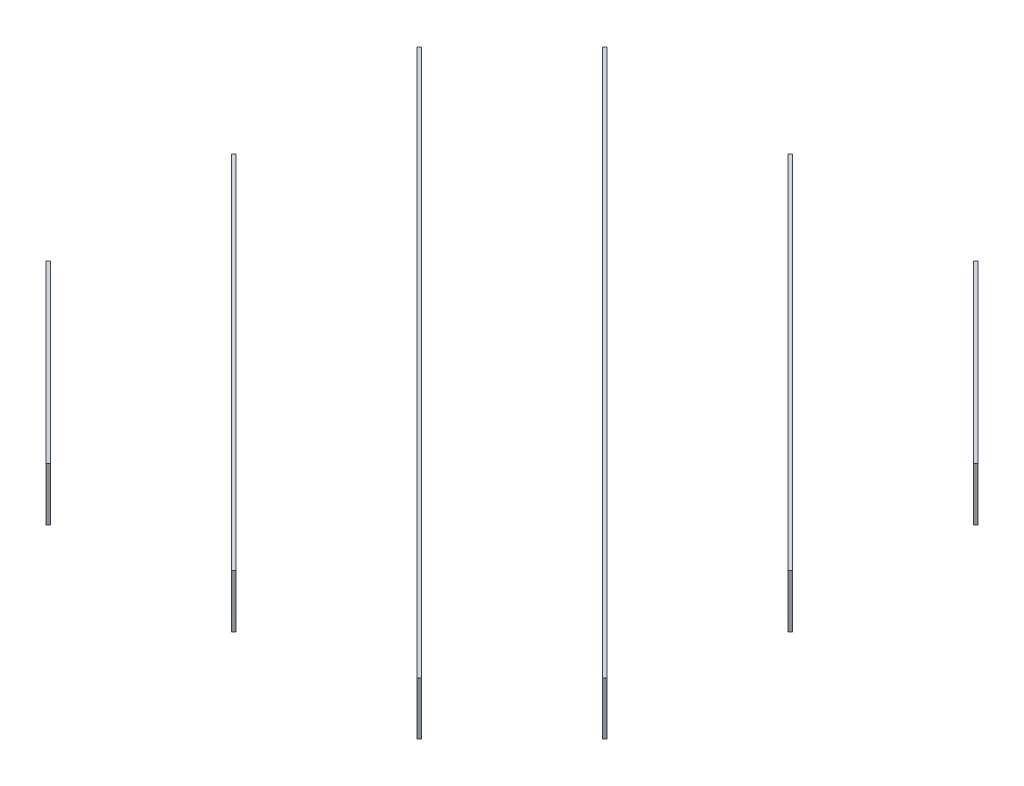
from build123d import *

# Parameters (mm, degrees)
BOSS_EXTRUDE1_DEPTH   = 100
BOSS_EXTRUDE1_2_DEPTH = 100
BOSS_EXTRUDE1_3_DEPTH = 100
BOSS_EXTRUDE1_4_DEPTH = 100
BOSS_EXTRUDE1_5_DEPTH = 100
BOSS_EXTRUDE1_6_DEPTH = 100
SKETCH3_R             = 1.5
SKETCH3_W             = 6
SKETCH3_H             = 100
CUT_EXTRUDE1_DEPTH    = 1478.317638774
SKETCH6_W             = 56
SKETCH6_H             = 12
CUT_EXTRUDE3_DEPTH    = 6
SKETCH7_W             = 56
SKETCH7_H             = 12
CUT_EXTRUDE4_DEPTH    = 6
SKETCH8_R             = 1.5
CUT_EXTRUDE5_DEPTH    = 1478.317638774
CUT_EXTRUDE6_START    = -253.487374
SKETCH9_R             = 4
CUT_EXTRUDE6_DEPTH    = 253.487374
CUT_EXTRUDE7_START    = -253.487374
SKETCH10_R            = 3
CUT_EXTRUDE7_DEPTH    = 253.487374
CUT_EXTRUDE8_START    = -253.487374
SKETCH11_R            = 3
CUT_EXTRUDE8_DEPTH    = 253.487374
SKETCH12_R            = 3
CUT_EXTRUDE9_DEPTH    = 748.46212
CUT_EXTRUDE10_START   = -253.487374
SKETCH13_R            = 3
CUT_EXTRUDE10_DEPTH   = 253.487374


with BuildPart() as part:
    # Sketch2 → Boss-Extrude1 (new body)
    with BuildSketch(Plane(origin=(0, 0, 0), x_dir=(1, 0, 0), z_dir=(0, 1, 0))):
        Polygon((-605, -274.242640687), (-274.242640687, -605), (-270, -600.757359313), (-600.757359313, -270), align=None)
    extrude(amount=BOSS_EXTRUDE1_DEPTH)


with BuildPart() as body_2:
    # Sketch2 → Boss-Extrude1 2 (new body)
    with BuildSketch(Plane(origin=(0, 0, 0), x_dir=(1, 0, 0), z_dir=(0, 1, 0))):
        Polygon((-605, 75.757359313), (75.757359313, -605), (80, -600.757359313), (-600.757359313, 80), align=None)
    extrude(amount=BOSS_EXTRUDE1_2_DEPTH)


with BuildPart() as body_3:
    # Sketch2 → Boss-Extrude1 3 (new body)
    with BuildSketch(Plane(origin=(0, 0, 0), x_dir=(1, 0, 0), z_dir=(0, 1, 0))):
        Polygon((-605, 425.757359313), (425.757359313, -605), (430, -600.757359313), (-600.757359313, 430), align=None)
    extrude(amount=BOSS_EXTRUDE1_3_DEPTH)


with BuildPart() as body_4:
    # Sketch2 → Boss-Extrude1 4 (new body)
    with BuildSketch(Plane(origin=(0, 0, 0), x_dir=(1, 0, 0), z_dir=(0, 1, 0))):
        Polygon((-430, 600.757359313), (600.757359313, -430), (605, -425.757359313), (-425.757359313, 605), align=None)
    extrude(amount=BOSS_EXTRUDE1_4_DEPTH)


with BuildPart() as body_5:
    # Sketch2 → Boss-Extrude1 5 (new body)
    with BuildSketch(Plane(origin=(0, 0, 0), x_dir=(1, 0, 0), z_dir=(0, 1, 0))):
        Polygon((-80, 600.757359313), (600.757359313, -80), (605, -75.757359313), (-75.757359313, 605), align=None)
    extrude(amount=BOSS_EXTRUDE1_5_DEPTH)


with BuildPart() as body_6:
    # Sketch2 → Boss-Extrude1 6 (new body)
    with BuildSketch(Plane(origin=(0, 0, 0), x_dir=(1, 0, 0), z_dir=(0, 1, 0))):
        Polygon((270, 600.757359313), (600.757359313, 270), (605, 274.242640687), (274.242640687, 605), align=None)
    extrude(amount=BOSS_EXTRUDE1_6_DEPTH)


with BuildPart() as cut_extrude1_tool:
    # Sketch3 → Cut-Extrude1 (new body, through all)
    with BuildSketch(Plane(origin=(-439.621320344, 0, 439.621320344), x_dir=(0.707106781, 0, 0.707106781), z_dir=(-0.707106781, 0, 0.707106781))):
        with Locations((-615.718433538, 50)):
            Circle(SKETCH3_R)
        with Locations((-621.718433538, 50)):
            Circle(SKETCH3_R)
        with Locations((-618.718433538, 0)):
            Rectangle(SKETCH3_W, SKETCH3_H)
        with BuildLine():
            Line((-621.718433538, 48.5), (-621.718433538, 50))
            Line((-621.718433538, 50), (-620.218433538, 50))
            ThreePointArc((-620.218433538, 50), (-622.77909371, 51.060660172), (-621.718433538, 48.5))
        make_face()
        with BuildLine():
            Line((-620.218433538, 50), (-621.718433538, 50))
            Line((-621.718433538, 50), (-621.718433538, 48.5))
            ThreePointArc((-621.718433538, 48.5), (-620.657773366, 48.939339828), (-620.218433538, 50))
        make_face()
        with BuildLine():
            ThreePointArc((-614.218433538, 50), (-615.718433538, 51.5), (-617.218433538, 50))
            Line((-617.218433538, 50), (-615.718433538, 50))
            Line((-615.718433538, 50), (-615.718433538, 48.5))
            ThreePointArc((-615.718433538, 48.5), (-614.657773366, 48.939339828), (-614.218433538, 50))
        make_face()
        with BuildLine():
            Line((-615.718433538, 50), (-617.218433538, 50))
            ThreePointArc((-617.218433538, 50), (-616.77909371, 48.939339828), (-615.718433538, 48.5))
            Line((-615.718433538, 48.5), (-615.718433538, 50))
        make_face()
        with BuildLine():
            Line((-374.231060123, 48.5), (-374.231060123, 50))
            Line((-374.231060123, 50), (-372.731060123, 50))
            ThreePointArc((-372.731060123, 50), (-375.291720295, 51.060660172), (-374.231060123, 48.5))
        make_face()
        with BuildLine():
            Line((-372.731060123, 50), (-374.231060123, 50))
            Line((-374.231060123, 50), (-374.231060123, 48.5))
            ThreePointArc((-374.231060123, 48.5), (-373.170399951, 48.939339828), (-372.731060123, 50))
        make_face()
        with Locations((-368.231060123, 50)):
            Circle(SKETCH3_R)
        with Locations((-374.231060123, 50)):
            Circle(SKETCH3_R)
        with Locations((-371.231060123, 0)):
            Rectangle(SKETCH3_W, SKETCH3_H)
        with BuildLine():
            ThreePointArc((-366.731060123, 50), (-368.231060123, 51.5), (-369.731060123, 50))
            Line((-369.731060123, 50), (-368.231060123, 50))
            Line((-368.231060123, 50), (-368.231060123, 48.5))
            ThreePointArc((-368.231060123, 48.5), (-367.170399951, 48.939339828), (-366.731060123, 50))
        make_face()
        with BuildLine():
            Line((-368.231060123, 50), (-369.731060123, 50))
            ThreePointArc((-369.731060123, 50), (-369.291720295, 48.939339828), (-368.231060123, 48.5))
            Line((-368.231060123, 48.5), (-368.231060123, 50))
        make_face()
        with BuildLine():
            Line((-126.705577884, 48.5), (-126.705577884, 50))
            Line((-126.705577884, 50), (-125.205577884, 50))
            ThreePointArc((-125.205577884, 50), (-127.766238056, 51.060660172), (-126.705577884, 48.5))
        make_face()
        with BuildLine():
            Line((-125.205577884, 50), (-126.705577884, 50))
            Line((-126.705577884, 50), (-126.705577884, 48.5))
            ThreePointArc((-126.705577884, 48.5), (-125.644917713, 48.939339828), (-125.205577884, 50))
        make_face()
        with BuildLine():
            ThreePointArc((-119.205577884, 50), (-120.705577884, 51.5), (-122.205577884, 50))
            Line((-122.205577884, 50), (-120.705577884, 50))
            Line((-120.705577884, 50), (-120.705577884, 48.5))
            ThreePointArc((-120.705577884, 48.5), (-119.644917713, 48.939339828), (-119.205577884, 50))
        make_face()
        with BuildLine():
            Line((-120.705577884, 50), (-122.205577884, 50))
            ThreePointArc((-122.205577884, 50), (-121.766238056, 48.939339828), (-120.705577884, 48.5))
            Line((-120.705577884, 48.5), (-120.705577884, 50))
        make_face()
        with BuildLine():
            Line((-122.205577884, 50), (-125.205577884, 50))
            ThreePointArc((-125.205577884, 50), (-125.644917713, 48.939339828), (-126.705577884, 48.5))
            Line((-126.705577884, 48.5), (-126.705577884, 0))
            Line((-126.705577884, 0), (-120.705577884, 0))
            Line((-120.705577884, 0), (-120.705577884, 48.5))
            ThreePointArc((-120.705577884, 48.5), (-121.766238056, 48.939339828), (-122.205577884, 50))
        make_face()
        with BuildLine():
            ThreePointArc((122.205577884, 50), (119.644917713, 51.060660172), (120.705577884, 48.5))
            Line((120.705577884, 48.5), (120.705577884, 50))
            Line((120.705577884, 50), (122.205577884, 50))
        make_face()
        with BuildLine():
            Line((120.705577884, 50), (120.705577884, 48.5))
            ThreePointArc((120.705577884, 48.5), (121.766238056, 48.939339828), (122.205577884, 50))
            Line((122.205577884, 50), (120.705577884, 50))
        make_face()
        with BuildLine():
            Line((120.705577884, 48.5), (120.705577884, 0))
            Line((120.705577884, 0), (126.705577884, 0))
            Line((126.705577884, 0), (126.705577884, 48.5))
            ThreePointArc((126.705577884, 48.5), (125.644917713, 48.939339828), (125.205577884, 50))
            Line((125.205577884, 50), (122.205577884, 50))
            ThreePointArc((122.205577884, 50), (121.766238056, 48.939339828), (120.705577884, 48.5))
        make_face()
        with BuildLine():
            ThreePointArc((125.205577884, 50), (125.644917713, 48.939339828), (126.705577884, 48.5))
            Line((126.705577884, 48.5), (126.705577884, 50))
            Line((126.705577884, 50), (125.205577884, 50))
        make_face()
        with BuildLine():
            Line((126.705577884, 50), (126.705577884, 48.5))
            ThreePointArc((126.705577884, 48.5), (127.766238056, 48.939339828), (128.205577884, 50))
            ThreePointArc((128.205577884, 50), (126.705577884, 51.5), (125.205577884, 50))
            Line((125.205577884, 50), (126.705577884, 50))
        make_face()
        with BuildLine():
            Line((369.731060123, 50), (368.231060123, 50))
            Line((368.231060123, 50), (368.231060123, 48.5))
            ThreePointArc((368.231060123, 48.5), (369.291720295, 48.939339828), (369.731060123, 50))
        make_face()
        with BuildLine():
            Line((368.231060123, 48.5), (368.231060123, 50))
            Line((368.231060123, 50), (369.731060123, 50))
            ThreePointArc((369.731060123, 50), (367.170399951, 51.060660172), (368.231060123, 48.5))
        make_face()
        with Locations((374.231060123, 50)):
            Circle(SKETCH3_R)
        with Locations((368.231060123, 50)):
            Circle(SKETCH3_R)
        with Locations((371.231060123, 0)):
            Rectangle(SKETCH3_W, SKETCH3_H)
        with BuildLine():
            ThreePointArc((375.731060123, 50), (374.231060123, 51.5), (372.731060123, 50))
            Line((372.731060123, 50), (374.231060123, 50))
            Line((374.231060123, 50), (374.231060123, 48.5))
            ThreePointArc((374.231060123, 48.5), (375.291720295, 48.939339828), (375.731060123, 50))
        make_face()
        with BuildLine():
            Line((374.231060123, 50), (372.731060123, 50))
            ThreePointArc((372.731060123, 50), (373.170399951, 48.939339828), (374.231060123, 48.5))
            Line((374.231060123, 48.5), (374.231060123, 50))
        make_face()
        with BuildLine():
            Line((617.218433538, 50), (615.718433538, 50))
            Line((615.718433538, 50), (615.718433538, 48.5))
            ThreePointArc((615.718433538, 48.5), (616.77909371, 48.939339828), (617.218433538, 50))
        make_face()
        with BuildLine():
            Line((615.718433538, 48.5), (615.718433538, 50))
            Line((615.718433538, 50), (617.218433538, 50))
            ThreePointArc((617.218433538, 50), (614.657773366, 51.060660172), (615.718433538, 48.5))
        make_face()
        with BuildLine():
            ThreePointArc((623.218433538, 50), (621.718433538, 51.5), (620.218433538, 50))
            Line((620.218433538, 50), (621.718433538, 50))
            Line((621.718433538, 50), (621.718433538, 48.5))
            ThreePointArc((621.718433538, 48.5), (622.77909371, 48.939339828), (623.218433538, 50))
        make_face()
        with BuildLine():
            Line((621.718433538, 50), (620.218433538, 50))
            ThreePointArc((620.218433538, 50), (620.657773366, 48.939339828), (621.718433538, 48.5))
            Line((621.718433538, 48.5), (621.718433538, 50))
        make_face()
        with Locations((621.718433538, 50)):
            Circle(SKETCH3_R)
        with Locations((615.718433538, 50)):
            Circle(SKETCH3_R)
        with Locations((618.718433538, 0)):
            Rectangle(SKETCH3_W, SKETCH3_H)
    extrude(amount=-CUT_EXTRUDE1_DEPTH)


with BuildPart() as part_1:
    add(part.part)

    # Cut-Extrude1: cut by cut_extrude1_tool
    add(cut_extrude1_tool.part, mode=Mode.SUBTRACT)


with BuildPart() as body_2_1:
    add(body_2.part)

    # Cut-Extrude1: cut by cut_extrude1_tool
    add(cut_extrude1_tool.part, mode=Mode.SUBTRACT)

    # Sketch7 → Cut-Extrude4 (cut)
    with BuildSketch(Plane(origin=(-264.621320344, 0, 264.621320344), x_dir=(0.707106781, 0, 0.707106781), z_dir=(-0.707106781, 0, 0.707106781))):
        with Locations((-0.019054412, 78)):
            Rectangle(SKETCH7_W, SKETCH7_H)
    extrude(amount=-CUT_EXTRUDE4_DEPTH, mode=Mode.SUBTRACT)


with BuildPart() as body_3_1:
    add(body_3.part)

    # Cut-Extrude1: cut by cut_extrude1_tool
    add(cut_extrude1_tool.part, mode=Mode.SUBTRACT)


with BuildPart() as body_4_1:
    add(body_4.part)

    # Cut-Extrude1: cut by cut_extrude1_tool
    add(cut_extrude1_tool.part, mode=Mode.SUBTRACT)


with BuildPart() as body_5_1:
    add(body_5.part)

    # Cut-Extrude1: cut by cut_extrude1_tool
    add(cut_extrude1_tool.part, mode=Mode.SUBTRACT)

    # Sketch6 → Cut-Extrude3 (cut)
    with BuildSketch(Plane(origin=(260.378679656, 0, -260.378679656), x_dir=(0.707106781, 0, 0.707106781), z_dir=(-0.707106781, 0, 0.707106781))):
        with Locations((-0.019054412, 78)):
            Rectangle(SKETCH6_W, SKETCH6_H)
    extrude(amount=-CUT_EXTRUDE3_DEPTH, mode=Mode.SUBTRACT)


with BuildPart() as body_6_1:
    add(body_6.part)

    # Cut-Extrude1: cut by cut_extrude1_tool
    add(cut_extrude1_tool.part, mode=Mode.SUBTRACT)


with BuildPart() as cut_extrude5_tool:
    # Sketch8 → Cut-Extrude5 (new body, through all)
    with BuildSketch(Plane(origin=(-439.621320344, 0, 439.621320344), x_dir=(0.707106781, 0, 0.707106781), z_dir=(-0.707106781, 0, 0.707106781))):
        Circle(SKETCH8_R)
    extrude(amount=-CUT_EXTRUDE5_DEPTH)


with BuildPart() as part_2:
    add(part_1.part)

    # Cut-Extrude5: cut by cut_extrude5_tool
    add(cut_extrude5_tool.part, mode=Mode.SUBTRACT)


with BuildPart() as body_2_2:
    add(body_2_1.part)

    # Cut-Extrude5: cut by cut_extrude5_tool
    add(cut_extrude5_tool.part, mode=Mode.SUBTRACT)


with BuildPart() as body_3_2:
    add(body_3_1.part)

    # Cut-Extrude5: cut by cut_extrude5_tool
    add(cut_extrude5_tool.part, mode=Mode.SUBTRACT)


with BuildPart() as body_4_2:
    add(body_4_1.part)

    # Cut-Extrude5: cut by cut_extrude5_tool
    add(cut_extrude5_tool.part, mode=Mode.SUBTRACT)


with BuildPart() as body_5_2:
    add(body_5_1.part)

    # Cut-Extrude5: cut by cut_extrude5_tool
    add(cut_extrude5_tool.part, mode=Mode.SUBTRACT)


with BuildPart() as body_6_2:
    add(body_6_1.part)

    # Cut-Extrude5: cut by cut_extrude5_tool
    add(cut_extrude5_tool.part, mode=Mode.SUBTRACT)


with BuildPart() as cut_extrude6_tool:
    # Sketch9 → Cut-Extrude6 (new body)
    with BuildSketch(Plane(origin=(-89.621320344, 0, 89.621320344), x_dir=(0.707106781, 0, 0.707106781), z_dir=(-0.707106781, 0, 0.707106781)).offset(CUT_EXTRUDE6_START)):
        with Locations((0, 16)):
            Circle(SKETCH9_R)
        with Locations((0, 36)):
            Circle(SKETCH9_R)
    extrude(amount=CUT_EXTRUDE6_DEPTH)


with BuildPart() as body_3_3:
    add(body_3_2.part)

    # Cut-Extrude6: cut by cut_extrude6_tool
    add(cut_extrude6_tool.part, mode=Mode.SUBTRACT)


with BuildPart() as body_4_3:
    add(body_4_2.part)

    # Cut-Extrude6: cut by cut_extrude6_tool
    add(cut_extrude6_tool.part, mode=Mode.SUBTRACT)


with BuildPart() as cut_extrude7_tool:
    # Sketch10 → Cut-Extrude7 (new body)
    with BuildSketch(Plane(origin=(439.621320344, 0, -439.621320344), x_dir=(-0.707106781, 0, -0.707106781), z_dir=(0.707106781, 0, -0.707106781)).offset(CUT_EXTRUDE7_START)):
        with Locations((0, 50)):
            Circle(SKETCH10_R)
    extrude(amount=CUT_EXTRUDE7_DEPTH)


with BuildPart() as body_5_3:
    add(body_5_2.part)

    # Cut-Extrude7: cut by cut_extrude7_tool
    add(cut_extrude7_tool.part, mode=Mode.SUBTRACT)


with BuildPart() as body_6_3:
    add(body_6_2.part)

    # Cut-Extrude7: cut by cut_extrude7_tool
    add(cut_extrude7_tool.part, mode=Mode.SUBTRACT)


with BuildPart() as cut_extrude8_tool:
    # Sketch11 → Cut-Extrude8 (new body)
    with BuildSketch(Plane(origin=(-439.621320344, 0, 439.621320344), x_dir=(0.707106781, 0, 0.707106781), z_dir=(-0.707106781, 0, 0.707106781)).offset(CUT_EXTRUDE8_START)):
        with Locations((0, 50)):
            Circle(SKETCH11_R)
    extrude(amount=CUT_EXTRUDE8_DEPTH)


with BuildPart() as part_3:
    add(part_2.part)

    # Cut-Extrude8: cut by cut_extrude8_tool
    add(cut_extrude8_tool.part, mode=Mode.SUBTRACT)


with BuildPart() as body_2_3:
    add(body_2_2.part)

    # Cut-Extrude8: cut by cut_extrude8_tool
    add(cut_extrude8_tool.part, mode=Mode.SUBTRACT)


with BuildPart() as cut_extrude9_tool:
    # Sketch12 → Cut-Extrude9 (new body)
    with BuildSketch(Plane(origin=(264.621320344, 0, -264.621320344), x_dir=(-0.707106781, 0, -0.707106781), z_dir=(0.707106781, 0, -0.707106781))):
        with Locations((247.468319004, 50)):
            Circle(SKETCH12_R)
    cut_extrude9 = extrude(amount=-CUT_EXTRUDE9_DEPTH)


with BuildPart() as body_2_4:
    add(body_2_3.part)

    # Cut-Extrude9: cut by cut_extrude9_tool
    add(cut_extrude9_tool.part, mode=Mode.SUBTRACT)


with BuildPart() as body_3_4:
    add(body_3_3.part)

    # Cut-Extrude9: cut by cut_extrude9_tool
    add(cut_extrude9_tool.part, mode=Mode.SUBTRACT)


with BuildPart() as body_4_4:
    add(body_4_3.part)

    # Cut-Extrude9: cut by cut_extrude9_tool
    add(cut_extrude9_tool.part, mode=Mode.SUBTRACT)


with BuildPart() as body_5_4:
    add(body_5_3.part)

    # Cut-Extrude9: cut by cut_extrude9_tool
    add(cut_extrude9_tool.part, mode=Mode.SUBTRACT)


with BuildPart() as cut_extrude10_tool:
    # Sketch13 → Cut-Extrude10 (new body)
    with BuildSketch(Plane(origin=(89.621320344, 0, -89.621320344), x_dir=(-0.707106781, 0, -0.707106781), z_dir=(0.707106781, 0, -0.707106781)).offset(CUT_EXTRUDE10_START)):
        with Locations((494.974746831, 50)):
            Circle(SKETCH13_R)
    cut_extrude10 = extrude(amount=CUT_EXTRUDE10_DEPTH)


with BuildPart() as body_3_5:
    add(body_3_4.part)

    # Cut-Extrude10: cut by cut_extrude10_tool
    add(cut_extrude10_tool.part, mode=Mode.SUBTRACT)


with BuildPart() as body_4_5:
    add(body_4_4.part)

    # Cut-Extrude10: cut by cut_extrude10_tool
    add(cut_extrude10_tool.part, mode=Mode.SUBTRACT)


with BuildPart() as mirror1_tool:
    # Mirror1: Cut-Extrude9, Cut-Extrude10 across plane
    add(cut_extrude9.mirror(Plane(origin=(0, 0, 0), x_dir=(-0.707106781, 0, 0.707106781), z_dir=(0.707106781, 0, 0.707106781))))
    add(cut_extrude10.mirror(Plane(origin=(0, 0, 0), x_dir=(-0.707106781, 0, 0.707106781), z_dir=(0.707106781, 0, 0.707106781))))


with BuildPart() as body_2_5:
    add(body_2_4.part)

    # Mirror1: cut by mirror1_tool
    add(mirror1_tool.part, mode=Mode.SUBTRACT)


with BuildPart() as body_3_6:
    add(body_3_5.part)

    # Mirror1: cut by mirror1_tool
    add(mirror1_tool.part, mode=Mode.SUBTRACT)


with BuildPart() as body_4_6:
    add(body_4_5.part)

    # Mirror1: cut by mirror1_tool
    add(mirror1_tool.part, mode=Mode.SUBTRACT)


with BuildPart() as body_5_5:
    add(body_5_4.part)

    # Mirror1: cut by mirror1_tool
    add(mirror1_tool.part, mode=Mode.SUBTRACT)


solid = Compound([body_6_3.part, part_3.part, body_2_5.part, body_3_6.part, body_4_6.part, body_5_5.part])
